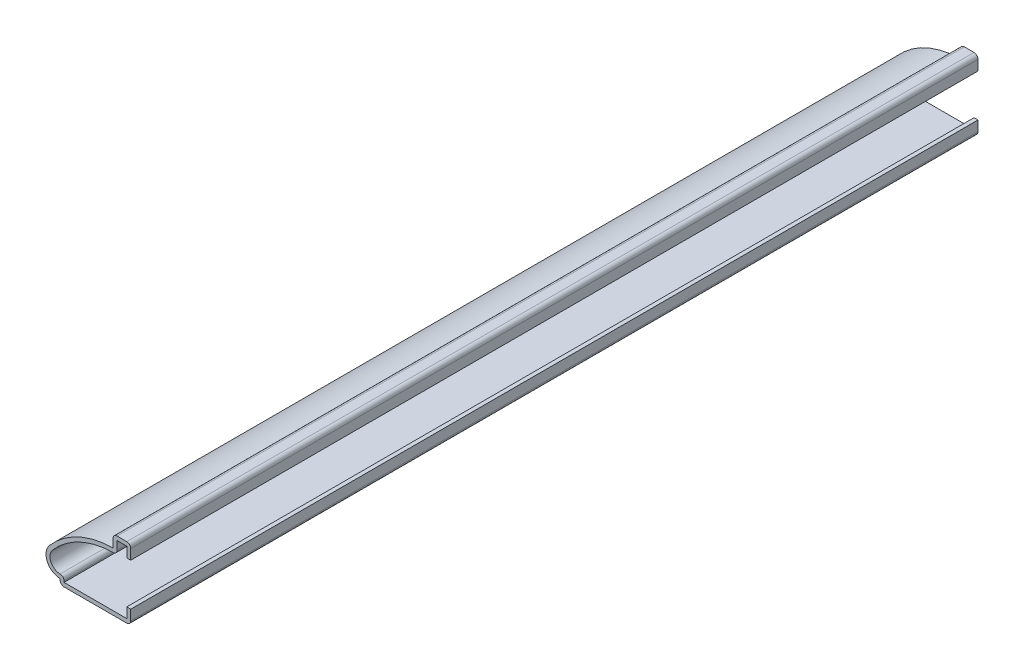
from build123d import *

# Parameters (mm, degrees)
EXTRUDE_THIN1_DEPTH = 190.5
FILLET1_R           = 0.889


with BuildPart() as part:
    # Sketch1 → Extrude-Thin1 (new body)
    with BuildSketch(Plane.XY):
        with BuildLine():
            Line((0, 0), (0, -3.175))
            Line((0, -3.175), (-15.875, -3.175))
            Line((-15.875, -3.175), (-15.875, -1.984375))
            ThreePointArc((-15.875, -1.984375), (-18.75880077, -0.137651371), (-18.287903573, 3.254243508))
            ThreePointArc((-18.287903573, 3.254243508), (-11.851948281, 8.142081446), (-3.96875, 9.921875))
            Line((-3.96875, 9.921875), (-3.96875, 12.7))
            Line((-3.96875, 12.7), (0, 12.7))
            Line((0, 12.7), (0, 9.525))
            Line((0, 9.525), (-0.889, 9.525))
            Line((-0.889, 9.525), (-0.889, 11.811))
            Line((-0.889, 11.811), (-3.07975, 11.811))
            Line((-3.07975, 11.811), (-3.07975, 9.01882551))
            ThreePointArc((-3.07975, 9.01882551), (-11.07476139, 7.517416594), (-17.612290572, 2.676430326))
            ThreePointArc((-17.612290572, 2.676430326), (-17.720336691, -0.158644616), (-14.986, -0.915431742))
            Line((-14.986, -0.915431742), (-14.986, -2.286))
            Line((-14.986, -2.286), (-0.889, -2.286))
            Line((-0.889, -2.286), (-0.889, 0))
            Line((-0.889, 0), (0, 0))
        make_face()
    extrude(amount=-EXTRUDE_THIN1_DEPTH)

    # Fillet1
    fillet1_edges = [part.edges().sort_by_distance(p)[0] for p in [
        (-3.07975, 9.01882551, -95.25),
        (-14.986, -0.915431742, -95.25),
        (0, -3.175, -95.25),
        (-15.875, -3.175, -95.25),
        (-3.96875, 12.7, -95.25),
        (0, 12.7, -95.25),
    ]]
    fillet(fillet1_edges, radius=FILLET1_R)


solid = part.part
